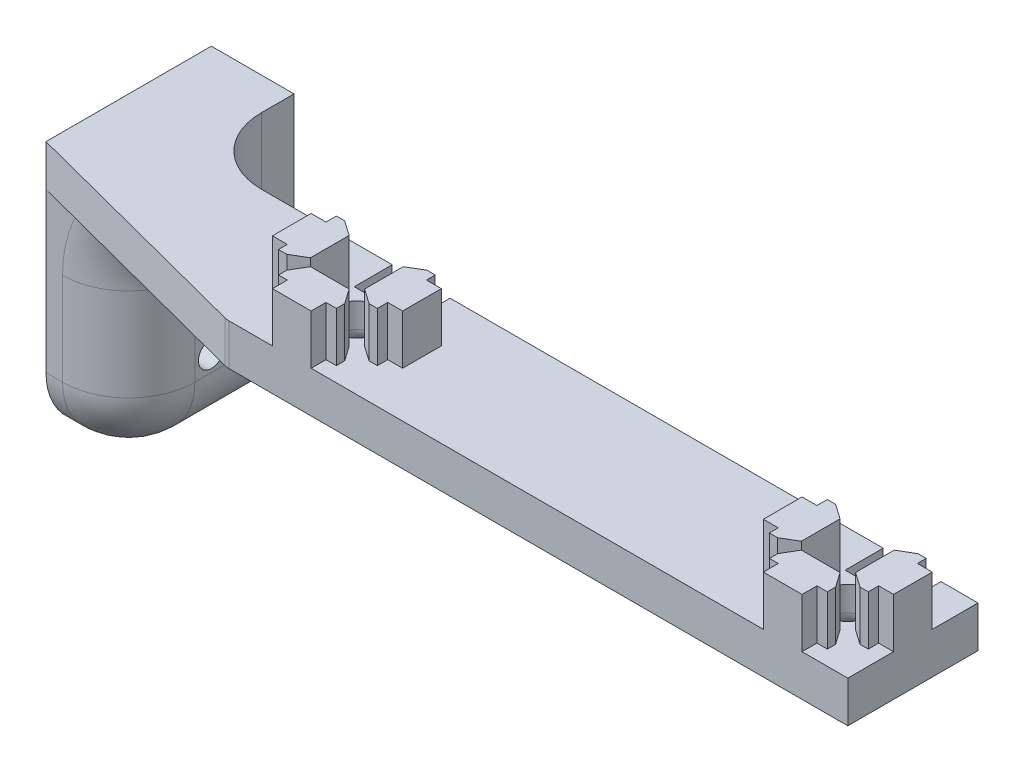
from build123d import *

# Parameters (mm, degrees)
BOSS_EXTRUDE1_DEPTH   = 7.62
BOSS_EXTRUDE1_2_DEPTH = 7.62
BOSS_EXTRUDE1_3_DEPTH = 7.62
BOSS_EXTRUDE1_4_DEPTH = 7.62
SKETCH2_W             = 132.9538108
SKETCH2_H             = 20
BOSS_EXTRUDE2_DEPTH   = 6.35
LPATTERN2_COUNT       = 2
LPATTERN2_PITCH       = 75.4126
CUT_EXTRUDE1_DEPTH    = 125.148300392
FILLET1_R             = 2.54
SKETCH13_R            = 3.5
CUT_EXTRUDE5_DEPTH    = 124.59491895
FILLET6_R             = 2.54
SKETCH14_W            = 8.89
SKETCH14_H            = 5.842
CUT_EXTRUDE6_DEPTH    = 125.148300392
SKETCH15_W            = 25.4
SKETCH15_H            = 40.894
BOSS_EXTRUDE3_DEPTH   = 12.7
FILLET15_R            = 10.16
FILLET16_R            = 10.16
FILLET17_R            = 10.16
FILLET18_R            = 10.16
SKETCH18_R            = 1.984375
CUT_EXTRUDE9_DEPTH    = 12.7


with BuildPart() as part:
    # Sketch1 → Boss-Extrude1 (new body)
    with BuildSketch(Plane(origin=(0, 0, 0), x_dir=(1, 0, 0), z_dir=(0, 1, 0))):
        Polygon((2.9718, 10), (-2.9718, 10), (-2.9718, 7.714), (-4.567901235, 7.714), (-4.567901235, 6.444), (-2.9718, 4.158), (2.9718, 4.158), (4.322098765, 6.444), (4.322098765, 7.714), (2.9718, 7.714), align=None)
    boss_extrude1 = extrude(amount=BOSS_EXTRUDE1_DEPTH)



with BuildPart() as body_2:
    # Sketch1 → Boss-Extrude1 2 (new body)
    with BuildSketch(Plane(origin=(0, 0, 0), x_dir=(1, 0, 0), z_dir=(0, 1, 0))):
        Polygon((4.158, -2.9718), (4.158, 2.9718), (6.444, 4.322098765), (7.714, 4.322098765), (7.714, 2.9718), (10, 2.9718), (10, -2.9718), (7.714, -2.9718), (7.714, -4.567901235), (6.444, -4.567901235), align=None)
    boss_extrude1_2 = extrude(amount=BOSS_EXTRUDE1_2_DEPTH)


with BuildPart() as body_3:
    # Sketch1 → Boss-Extrude1 3 (new body)
    with BuildSketch(Plane(origin=(0, 0, 0), x_dir=(1, 0, 0), z_dir=(0, 1, 0))):
        Polygon((-10, -2.9718), (-10, 2.9718), (-7.714, 2.9718), (-7.714, 4.567901235), (-6.444, 4.567901235), (-4.158, 2.9718), (-4.158, -2.9718), (-6.444, -4.322098765), (-7.714, -4.322098765), (-7.714, -2.9718), align=None)
    boss_extrude1_3 = extrude(amount=BOSS_EXTRUDE1_3_DEPTH)


with BuildPart() as body_4:
    # Sketch1 → Boss-Extrude1 4 (new body)
    with BuildSketch(Plane(origin=(0, 0, 0), x_dir=(1, 0, 0), z_dir=(0, 1, 0))):
        Polygon((4.567901235, -6.444), (2.9718, -4.158), (-2.9718, -4.158), (-4.322098765, -6.444), (-4.322098765, -7.714), (-2.9718, -7.714), (-2.9718, -10), (2.9718, -10), (2.9718, -7.714), (4.567901235, -7.714), align=None)
    boss_extrude1_4 = extrude(amount=BOSS_EXTRUDE1_4_DEPTH)


with BuildPart() as part_1:
    add(part.part)

    add(body_2.part)  # Boss-Extrude2 merges body 2

    add(body_3.part)  # Boss-Extrude2 merges body 3

    add(body_4.part)  # Boss-Extrude2 merges body 4
    # Sketch2 → Boss-Extrude2 (add)
    with BuildSketch(Plane.XZ):
        with Locations((-56.4769054, 0)):
            Rectangle(SKETCH2_W, SKETCH2_H)
    extrude(amount=BOSS_EXTRUDE2_DEPTH)

    # LPattern2: Boss-Extrude1, Boss-Extrude1 2, Boss-Extrude1 3, Boss-Extrude1 4 ×2
    with Locations(*[(-i * LPATTERN2_PITCH, 0, 0) for i in range(1, LPATTERN2_COUNT)]):
        add(boss_extrude1)
        add(boss_extrude1_2)
        add(boss_extrude1_3)
        add(boss_extrude1_4)

    # Sketch4 → Cut-Extrude1 (cut, through all)
    with BuildSketch(Plane(origin=(0, -6.35, 0), x_dir=(-1, 0, 0), z_dir=(0, -1, 0))):
        Polygon((122.9538108, -10), (85.4126108, -10), (122.9538108, -0.2108), align=None)
    extrude(amount=-CUT_EXTRUDE1_DEPTH, mode=Mode.SUBTRACT)

    # Fillet1
    fillet1_edges = [part_1.edges().sort_by_distance(p)[0] for p in [
        (-85.4126108, -3.175, 10),
    ]]
    fillet(fillet1_edges, radius=FILLET1_R)

    # Sketch13 → Cut-Extrude5 (cut, through all)
    with BuildSketch(Plane(origin=(0, 0, 0), x_dir=(1, 0, 0), z_dir=(0, 1, 0))):
        with Locations(Location((0, 0, 0), (0, 0, 270))):
            Circle(SKETCH13_R)
        with Locations(Location((-75.4126, 0, 0), (0, 0, 270))):
            Circle(SKETCH13_R)
    extrude(amount=-CUT_EXTRUDE5_DEPTH, mode=Mode.SUBTRACT)

    # Fillet6
    fillet6_edges = [part_1.edges().sort_by_distance(p)[0] for p in [
        (0, -6.35, -3.5),
        (-75.4126, -6.35, -3.5),
    ]]
    fillet(fillet6_edges, radius=FILLET6_R)

    # Sketch14 → Cut-Extrude6 (cut, through all)
    with BuildSketch(Plane(origin=(0, 7.62, 0), x_dir=(1, 0, 0), z_dir=(0, 1, 0))):
        with Locations((-0.122901235, 7.079)):
            Rectangle(SKETCH14_W, SKETCH14_H)
        with Locations((-75.535501235, 7.079)):
            Rectangle(SKETCH14_W, SKETCH14_H)
    extrude(amount=-CUT_EXTRUDE6_DEPTH, mode=Mode.SUBTRACT)

    # Sketch15 → Boss-Extrude3 (add)
    with BuildSketch(Plane.ZY.offset(122.9538108)):
        with Locations((-12.4892, -20.447)):
            Rectangle(SKETCH15_W, SKETCH15_H)
    extrude(amount=-BOSS_EXTRUDE3_DEPTH)

    # Fillet15
    fillet15_edges = [part_1.edges().sort_by_distance(p)[0] for p in [
        (-110.2538108, -6.35, -4.8946),
    ]]
    fillet(fillet15_edges, radius=FILLET15_R)

    # Fillet16
    fillet16_edges = [part_1.edges().sort_by_distance(p)[0] for p in [
        (-110.2538108, -8.255, -10),
    ]]
    fillet(fillet16_edges, radius=FILLET16_R)

    # Fillet17
    fillet17_edges = [part_1.edges().sort_by_distance(p)[0] for p in [
        (-110.2538108, -40.894, -12.4892),
    ]]
    fillet(fillet17_edges, radius=FILLET17_R)

    # Fillet18
    fillet18_edges = [part_1.edges().sort_by_distance(p)[0] for p in [
        (-107.278015697, -9.325795103, 0.2108),
        (-121.6838108, -40.894, 0.2108),
        (-110.2538108, -23.622, 0.2108),
        (-113.229605903, -37.918204897, 0.2108),
    ]]
    fillet(fillet18_edges, radius=FILLET18_R)

    # Sketch18 → Cut-Extrude9 (cut)
    with BuildSketch(Plane.ZY.offset(122.9538108)):
        with Locations((-12.4892, -28.194)):
            Circle(SKETCH18_R)
    extrude(amount=-CUT_EXTRUDE9_DEPTH, mode=Mode.SUBTRACT)


solid = part_1.part
